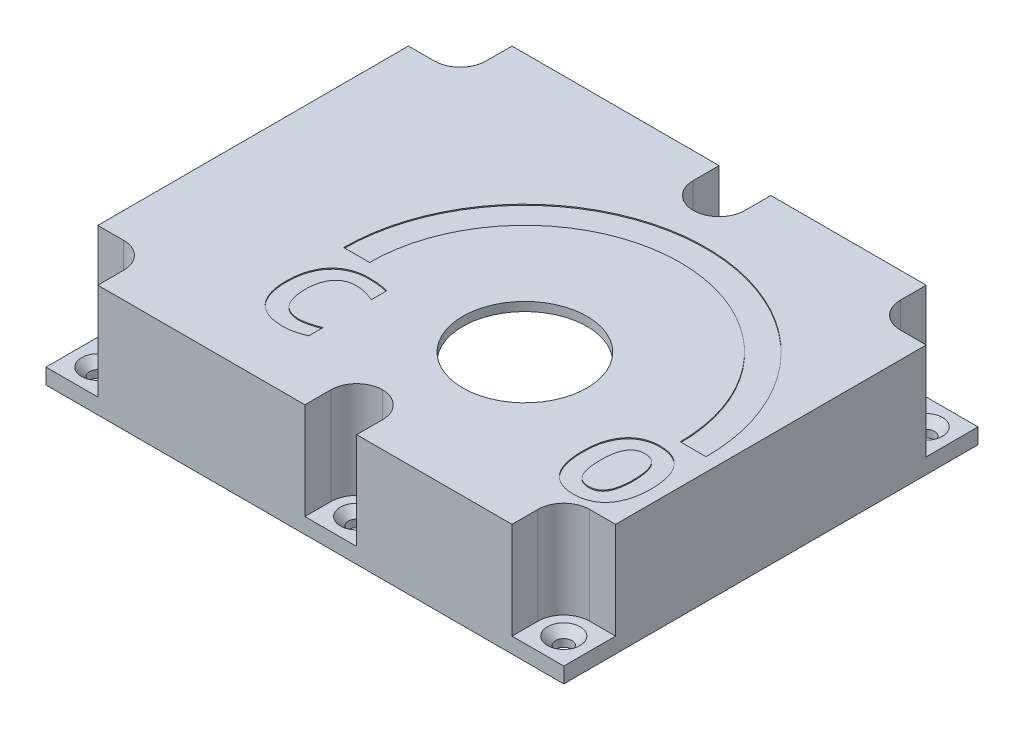
from build123d import *

# Parameters (mm, degrees)
BOSS_EXTRUDE4_DEPTH                          = 20
BOSS_EXTRUDE5_DEPTH                          = 3
BOSS_EXTRUDE6_DEPTH                          = 1.7
CSK_FOR_M3_COUNTERSUNK_FLAT_HEAD_SCR_2_COUNT = 2
CSK_FOR_M3_COUNTERSUNK_FLAT_HEAD_SCR_2_PITCH = 89.998
CSK_FOR_M3_COUNTERSUNK_FLAT_HEAD_SCR_3_COUNT = 2
CSK_FOR_M3_COUNTERSUNK_FLAT_HEAD_SCR_3_PITCH = 114.014735925
CSK_FOR_M3_COUNTERSUNK_FLAT_HEAD_SCR_4_COUNT = 2
CSK_FOR_M3_COUNTERSUNK_FLAT_HEAD_SCR_4_PITCH = 69.998
CSK_FOR_M3_COUNTERSUNK_FLAT_HEAD_SCR_5_COUNT = 2
CSK_FOR_M3_COUNTERSUNK_FLAT_HEAD_SCR_5_PITCH = 86.020462728
CSK_FOR_M3_COUNTERSUNK_FLAT_HEAD_SCR_6_COUNT = 2
CSK_FOR_M3_COUNTERSUNK_FLAT_HEAD_SCR_6_PITCH = 49.998
SKETCH7_R                                    = 12
CUT_EXTRUDE1_DEPTH                           = 69.856850528
CUT_EXTRUDE2_DEPTH                           = 0.2


with BuildPart() as part:
    # Sketch1 → Boss-Extrude4 (new body)
    with BuildSketch(Plane(origin=(0, 0, 0), x_dir=(1, 0, 0), z_dir=(0, 1, 0))):
        with BuildLine():
            Line((-49.242001852, 28.84175066), (-44.241001852, 28.84175066))
            ThreePointArc((-44.241001852, 28.84175066), (-40.706175053, 30.305923861), (-39.242001852, 33.84075066))
            Line((-39.242001852, 33.84075066), (-39.242001852, 38.84175066))
            Line((-39.242001852, 38.84175066), (0.757998148, 38.84175066))
            Line((0.757998148, 38.84175066), (0.757998148, 33.84075066))
            ThreePointArc((0.757998148, 33.84075066), (2.222171348, 30.305923861), (5.756998148, 28.84175066))
            Line((5.756998148, 28.84175066), (5.758998148, 28.84175066))
            ThreePointArc((5.758998148, 28.84175066), (9.293824947, 30.305923861), (10.757998148, 33.84075066))
            Line((10.757998148, 33.84075066), (10.757998148, 38.84175066))
            Line((10.757998148, 38.84175066), (40.757998148, 38.84175066))
            Line((40.757998148, 38.84175066), (40.757998148, 33.84075066))
            ThreePointArc((40.757998148, 33.84075066), (42.222171348, 30.305923861), (45.756998148, 28.84175066))
            Line((45.756998148, 28.84175066), (50.757998148, 28.84175066))
            Line((50.757998148, 28.84175066), (50.757998148, -31.15824934))
            Line((50.757998148, -31.15824934), (45.756998148, -31.15824934))
            ThreePointArc((45.756998148, -31.15824934), (42.222171348, -32.62242254), (40.757998148, -36.15724934))
            Line((40.757998148, -36.15724934), (40.757998148, -41.15824934))
            Line((40.757998148, -41.15824934), (10.757998148, -41.15824934))
            Line((10.757998148, -41.15824934), (10.757998148, -36.15724934))
            ThreePointArc((10.757998148, -36.15724934), (9.293824947, -32.62242254), (5.758998148, -31.15824934))
            Line((5.758998148, -31.15824934), (5.756998148, -31.15824934))
            ThreePointArc((5.756998148, -31.15824934), (2.222171348, -32.62242254), (0.757998148, -36.15724934))
            Line((0.757998148, -36.15724934), (0.757998148, -41.15824934))
            Line((0.757998148, -41.15824934), (-39.242001852, -41.15824934))
            Line((-39.242001852, -41.15824934), (-39.242001852, -36.15724934))
            ThreePointArc((-39.242001852, -36.15724934), (-40.706175053, -32.62242254), (-44.241001852, -31.15824934))
            Line((-44.241001852, -31.15824934), (-49.242001852, -31.15824934))
            Line((-49.242001852, -31.15824934), (-49.242001852, 28.84175066))
        make_face()
        with BuildLine():
            Line((-47.742001852, 27.34175066), (-44.241001852, 27.34175066))
            ThreePointArc((-44.241001852, 27.34175066), (-39.645514881, 29.245263689), (-37.742001852, 33.84075066))
            Line((-37.742001852, 33.84075066), (-37.742001852, 37.34175066))
            Line((-37.742001852, 37.34175066), (-0.742001852, 37.34175066))
            Line((-0.742001852, 37.34175066), (-0.742001852, 33.84075066))
            ThreePointArc((-0.742001852, 33.84075066), (1.161511177, 29.245263689), (5.756998148, 27.34175066))
            Line((5.756998148, 27.34175066), (5.758998148, 27.34175066))
            ThreePointArc((5.758998148, 27.34175066), (10.354485119, 29.245263689), (12.257998148, 33.84075066))
            Line((12.257998148, 33.84075066), (12.257998148, 37.34175066))
            Line((12.257998148, 37.34175066), (39.257998148, 37.34175066))
            Line((39.257998148, 37.34175066), (39.257998148, 33.84075066))
            ThreePointArc((39.257998148, 33.84075066), (41.161511177, 29.245263689), (45.756998148, 27.34175066))
            Line((45.756998148, 27.34175066), (49.257998148, 27.34175066))
            Line((49.257998148, 27.34175066), (49.257998148, -29.65824934))
            Line((49.257998148, -29.65824934), (45.756998148, -29.65824934))
            ThreePointArc((45.756998148, -29.65824934), (41.161511177, -31.561762369), (39.257998148, -36.15724934))
            Line((39.257998148, -36.15724934), (39.257998148, -39.65824934))
            Line((39.257998148, -39.65824934), (12.257998148, -39.65824934))
            Line((12.257998148, -39.65824934), (12.257998148, -36.15724934))
            ThreePointArc((12.257998148, -36.15724934), (10.354485119, -31.561762369), (5.758998148, -29.65824934))
            Line((5.758998148, -29.65824934), (5.756998148, -29.65824934))
            ThreePointArc((5.756998148, -29.65824934), (1.161511177, -31.561762369), (-0.742001852, -36.15724934))
            Line((-0.742001852, -36.15724934), (-0.742001852, -39.65824934))
            Line((-0.742001852, -39.65824934), (-37.742001852, -39.65824934))
            Line((-37.742001852, -39.65824934), (-37.742001852, -36.15724934))
            ThreePointArc((-37.742001852, -36.15724934), (-39.645514881, -31.561762369), (-44.241001852, -29.65824934))
            Line((-44.241001852, -29.65824934), (-47.742001852, -29.65824934))
            Line((-47.742001852, -29.65824934), (-47.742001852, 27.34175066))
        make_face(mode=Mode.SUBTRACT)
    extrude(amount=BOSS_EXTRUDE4_DEPTH)

    # Sketch2 → Boss-Extrude5 (add)
    with BuildSketch(Plane.XZ):
        with BuildLine():
            Line((0.757998148, -38.84175066), (10.757998148, -38.84175066))
            Line((10.757998148, -38.84175066), (10.757998148, -33.84075066))
            ThreePointArc((10.757998148, -33.84075066), (9.293824947, -30.305923861), (5.758998148, -28.84175066))
            Line((5.758998148, -28.84175066), (5.756998148, -28.84175066))
            ThreePointArc((5.756998148, -28.84175066), (2.222171348, -30.305923861), (0.757998148, -33.84075066))
            Line((0.757998148, -33.84075066), (0.757998148, -38.84175066))
        make_face()
        with BuildLine():
            Line((-49.242001852, -38.84175066), (-39.242001852, -38.84175066))
            Line((-39.242001852, -38.84175066), (-39.242001852, -33.84075066))
            ThreePointArc((-39.242001852, -33.84075066), (-40.706175053, -30.305923861), (-44.241001852, -28.84175066))
            Line((-44.241001852, -28.84175066), (-49.242001852, -28.84175066))
            Line((-49.242001852, -28.84175066), (-49.242001852, -38.84175066))
        make_face()
        with BuildLine():
            Line((-49.242001852, 41.15824934), (-39.242001852, 41.15824934))
            Line((-39.242001852, 41.15824934), (-39.242001852, 36.15724934))
            ThreePointArc((-39.242001852, 36.15724934), (-40.706175053, 32.62242254), (-44.241001852, 31.15824934))
            Line((-44.241001852, 31.15824934), (-49.242001852, 31.15824934))
            Line((-49.242001852, 31.15824934), (-49.242001852, 41.15824934))
        make_face()
        with BuildLine():
            Line((50.757998148, 41.15824934), (40.757998148, 41.15824934))
            Line((40.757998148, 41.15824934), (40.757998148, 36.15724934))
            ThreePointArc((40.757998148, 36.15724934), (42.222171348, 32.62242254), (45.756998148, 31.15824934))
            Line((45.756998148, 31.15824934), (50.757998148, 31.15824934))
            Line((50.757998148, 31.15824934), (50.757998148, 41.15824934))
        make_face()
        with BuildLine():
            Line((50.757998148, -38.84175066), (40.757998148, -38.84175066))
            Line((40.757998148, -38.84175066), (40.757998148, -33.84075066))
            ThreePointArc((40.757998148, -33.84075066), (42.222171348, -30.305923861), (45.756998148, -28.84175066))
            Line((45.756998148, -28.84175066), (50.757998148, -28.84175066))
            Line((50.757998148, -28.84175066), (50.757998148, -38.84175066))
        make_face()
        with BuildLine():
            Line((0.757998148, 41.15824934), (10.757998148, 41.15824934))
            Line((10.757998148, 41.15824934), (10.757998148, 36.15724934))
            ThreePointArc((10.757998148, 36.15724934), (9.293824947, 32.62242254), (5.758998148, 31.15824934))
            Line((5.758998148, 31.15824934), (5.756998148, 31.15824934))
            ThreePointArc((5.756998148, 31.15824934), (2.222171348, 32.62242254), (0.757998148, 36.15724934))
            Line((0.757998148, 36.15724934), (0.757998148, 41.15824934))
        make_face()
    extrude(amount=-BOSS_EXTRUDE5_DEPTH)

    # Sketch3 → Boss-Extrude6 (add)
    with BuildSketch(Plane(origin=(0, 20, 0), x_dir=(1, 0, 0), z_dir=(0, 1, 0))):
        with BuildLine():
            ThreePointArc((0.757998148, 33.84075066), (2.222171348, 30.305923861), (5.756998148, 28.84175066))
            Line((5.756998148, 28.84175066), (5.758998148, 28.84175066))
            ThreePointArc((5.758998148, 28.84175066), (9.293824947, 30.305923861), (10.757998148, 33.84075066))
            Line((10.757998148, 33.84075066), (10.757998148, 38.84175066))
            Line((10.757998148, 38.84175066), (40.757998148, 38.84175066))
            Line((40.757998148, 38.84175066), (40.757998148, 33.84075066))
            ThreePointArc((40.757998148, 33.84075066), (42.222171348, 30.305923861), (45.756998148, 28.84175066))
            Line((45.756998148, 28.84175066), (50.757998148, 28.84175066))
            Line((50.757998148, 28.84175066), (50.757998148, -31.15824934))
            Line((50.757998148, -31.15824934), (45.756998148, -31.15824934))
            ThreePointArc((45.756998148, -31.15824934), (42.222171348, -32.62242254), (40.757998148, -36.15724934))
            Line((40.757998148, -36.15724934), (40.757998148, -41.15824934))
            Line((40.757998148, -41.15824934), (10.757998148, -41.15824934))
            Line((10.757998148, -41.15824934), (10.757998148, -36.15724934))
            ThreePointArc((10.757998148, -36.15724934), (9.293824947, -32.62242254), (5.758998148, -31.15824934))
            Line((5.758998148, -31.15824934), (5.756998148, -31.15824934))
            ThreePointArc((5.756998148, -31.15824934), (2.222171348, -32.62242254), (0.757998148, -36.15724934))
            Line((0.757998148, -36.15724934), (0.757998148, -41.15824934))
            Line((0.757998148, -41.15824934), (-39.242001852, -41.15824934))
            Line((-39.242001852, -41.15824934), (-39.242001852, -36.15724934))
            ThreePointArc((-39.242001852, -36.15724934), (-40.706175053, -32.62242254), (-44.241001852, -31.15824934))
            Line((-44.241001852, -31.15824934), (-49.242001852, -31.15824934))
            Line((-49.242001852, -31.15824934), (-49.242001852, 28.84175066))
            Line((-49.242001852, 28.84175066), (-44.241001852, 28.84175066))
            ThreePointArc((-44.241001852, 28.84175066), (-40.706175053, 30.305923861), (-39.242001852, 33.84075066))
            Line((-39.242001852, 33.84075066), (-39.242001852, 38.84175066))
            Line((-39.242001852, 38.84175066), (0.757998148, 38.84175066))
            Line((0.757998148, 38.84175066), (0.757998148, 33.84075066))
        make_face()
    extrude(amount=BOSS_EXTRUDE6_DEPTH)

    # Sketch5 → CSK for M3 Countersunk Flat Head Screw1 (revolve, cut)
    with BuildSketch(Plane(origin=(-44.241001852, 3, -33.84075066), x_dir=(0, 0, 1), z_dir=(1, 0, 0))):
        Polygon((0, 0), (0, 3), (1.6, 3), (1.6, 1.55), (3.15, 0), align=None)
    csk_for_m3_countersunk_flat_head_screw1 = revolve(axis=Axis((-44.241001852, 9.35, -33.84075066), (0, -1, 0)), mode=Mode.SUBTRACT)

    # CSK for M3 Countersunk Flat Head Scr 2: CSK for M3 Countersunk Flat Head Screw1 ×2
    with Locations(*[(i * CSK_FOR_M3_COUNTERSUNK_FLAT_HEAD_SCR_2_PITCH, 0, 0) for i in range(1, CSK_FOR_M3_COUNTERSUNK_FLAT_HEAD_SCR_2_COUNT)]):
        add(csk_for_m3_countersunk_flat_head_screw1, mode=Mode.SUBTRACT)

    # CSK for M3 Countersunk Flat Head Scr 3: CSK for M3 Countersunk Flat Head Screw1 ×2
    with Locations(*[Vector(0.789354106467132, 0, 0.6139381846761739) * (i * CSK_FOR_M3_COUNTERSUNK_FLAT_HEAD_SCR_3_PITCH) for i in range(1, CSK_FOR_M3_COUNTERSUNK_FLAT_HEAD_SCR_3_COUNT)]):
        add(csk_for_m3_countersunk_flat_head_screw1, mode=Mode.SUBTRACT)

    # CSK for M3 Countersunk Flat Head Scr 4: CSK for M3 Countersunk Flat Head Screw1 ×2
    with Locations(*[(0, 0, i * CSK_FOR_M3_COUNTERSUNK_FLAT_HEAD_SCR_4_PITCH) for i in range(1, CSK_FOR_M3_COUNTERSUNK_FLAT_HEAD_SCR_4_COUNT)]):
        add(csk_for_m3_countersunk_flat_head_screw1, mode=Mode.SUBTRACT)

    # CSK for M3 Countersunk Flat Head Scr 5: CSK for M3 Countersunk Flat Head Screw1 ×2
    with Locations(*[Vector(0.5812337950086401, 0, 0.8137366131248208) * (i * CSK_FOR_M3_COUNTERSUNK_FLAT_HEAD_SCR_5_PITCH) for i in range(1, CSK_FOR_M3_COUNTERSUNK_FLAT_HEAD_SCR_5_COUNT)]):
        add(csk_for_m3_countersunk_flat_head_screw1, mode=Mode.SUBTRACT)

    # CSK for M3 Countersunk Flat Head Scr 6: CSK for M3 Countersunk Flat Head Screw1 ×2
    with Locations(*[(i * CSK_FOR_M3_COUNTERSUNK_FLAT_HEAD_SCR_6_PITCH, 0, 0) for i in range(1, CSK_FOR_M3_COUNTERSUNK_FLAT_HEAD_SCR_6_COUNT)]):
        add(csk_for_m3_countersunk_flat_head_screw1, mode=Mode.SUBTRACT)

    # Sketch7 → Cut-Extrude1 (cut, through all)
    with BuildSketch(Plane(origin=(0, 21.7, 0), x_dir=(1, 0, 0), z_dir=(0, 1, 0))):
        with Locations(Location((13.196395148, -11.10824934, 0), (0, 0, 270))):
            Circle(SKETCH7_R)
    extrude(amount=-CUT_EXTRUDE1_DEPTH, mode=Mode.SUBTRACT)

    # Sketch8 → Cut-Extrude2 (cut)
    with BuildSketch(Plane(origin=(0, 21.7, 0), x_dir=(1, 0, 0), z_dir=(0, 1, 0))):
        with BuildLine():
            Line((-21.803604852, -11.10824934), (-16.803604852, -11.10824934))
            ThreePointArc((-16.803604852, -11.10824934), (13.196395148, 18.89175066), (43.196395148, -11.10824934))
            Line((43.196395148, -11.10824934), (48.196395148, -11.10824934))
            ThreePointArc((48.196395148, -11.10824934), (13.196395148, 23.89175066), (-21.803604852, -11.10824934))
        make_face()
        with BuildLine():
            add(Edge.make_bspline(
                [(-10.396498961, -29.259797973), (-10.573314527, -29.335278245), (-10.920221238, -29.48336822), (-11.444570062, -29.671129892), (-11.959348773, -29.831566568), (-12.469472256, -29.962814931), (-12.98054775, -30.067349926), (-13.499084516, -30.132721024), (-14.027284378, -30.179669837), (-14.383105842, -30.184758925), (-14.563165627, -30.187334205)],
                knots=[0, 0, 0, 0, 1.072602722, 2.104413604, 3.106297595, 4.08050826, 5.042709706, 6.014913564, 6.995467464, 8, 8, 8, 8], degree=3))
            add(Edge.make_bspline(
                [(-14.563165627, -30.187334205), (-14.844837842, -30.181169268), (-15.391718815, -30.169199729), (-16.188564586, -30.073701447), (-16.934741206, -29.915932829), (-17.632891547, -29.695682978), (-18.277842104, -29.407901385), (-18.872657472, -29.058520638), (-19.416216233, -28.647462597), (-19.904749664, -28.17249708), (-20.339115032, -27.636928751), (-20.712222144, -27.035932958), (-21.035722157, -26.378842147), (-21.300038931, -25.659761229), (-21.505712873, -24.88080498), (-21.651445503, -24.041987971), (-21.744612489, -23.143539517), (-21.753985988, -22.524533076), (-21.758817801, -22.205450147)],
                knots=[0, 0, 0, 0, 1.102605573, 2.140764961, 3.136846793, 4.08496906, 5.001529512, 5.896051515, 6.780328523, 7.66316301, 8.557497515, 9.473264751, 10.427030373, 11.420482266, 12.467702166, 13.577100782, 14.751053738, 16, 16, 16, 16], degree=3))
            add(Edge.make_bspline(
                [(-21.758817801, -22.205450147), (-21.753020793, -21.877873923), (-21.741720306, -21.239308133), (-21.64068115, -20.310656542), (-21.485903156, -19.435444011), (-21.255249511, -18.61948282), (-20.971529992, -17.858758099), (-20.625119114, -17.161267504), (-20.230584606, -16.52061109), (-19.774598046, -15.945511472), (-19.266115236, -15.431674365), (-18.703110104, -14.983821646), (-18.092449887, -14.596458925), (-17.427230473, -14.281090705), (-16.716558276, -14.032181855), (-15.962162969, -13.849280887), (-15.163954116, -13.744463707), (-14.617819052, -13.730637005), (-14.338527946, -13.723566089)],
                knots=[0, 0, 0, 0, 1.232307787, 2.402218284, 3.511138658, 4.573037126, 5.588482404, 6.562047137, 7.499038646, 8.414657469, 9.317692522, 10.213424542, 11.116219401, 12.033010505, 12.977368732, 13.94518829, 14.949178196, 16, 16, 16, 16], degree=3))
            add(Edge.make_bspline(
                [(-14.338527946, -13.723566089), (-14.159751698, -13.723403967), (-13.812965973, -13.723089488), (-13.305838054, -13.745265677), (-12.819430822, -13.764983228), (-12.343931668, -13.817102901), (-11.869265438, -13.874419396), (-11.389814283, -13.964024422), (-10.895703153, -14.055867222), (-10.56510249, -14.142931939), (-10.396498961, -14.187334205)],
                knots=[0, 0, 0, 0, 1.077376558, 2.089868288, 3.059369192, 4.010411707, 4.972009834, 5.940198088, 6.949518525, 8, 8, 8, 8], degree=3))
            Line((-10.396498961, -14.187334205), (-10.396498961, -17.201826959))
            add(Edge.make_bspline(
                [(-10.396498961, -17.201826959), (-10.569545275, -17.122473778), (-10.908395722, -16.967088436), (-11.421302513, -16.773426911), (-11.919172753, -16.60694656), (-12.406092719, -16.486678353), (-12.872549614, -16.390860897), (-13.320279318, -16.326209797), (-13.745944181, -16.284176232), (-14.0232221, -16.277513932), (-14.157368526, -16.274290727)],
                knots=[0, 0, 0, 0, 1.170030163, 2.291093263, 3.368831198, 4.395296508, 5.372370687, 6.295361994, 7.175300008, 8, 8, 8, 8], degree=3))
            add(Edge.make_bspline(
                [(-14.157368526, -16.274290727), (-14.343626832, -16.278839992), (-14.703318662, -16.287625284), (-15.222789202, -16.36404356), (-15.700199105, -16.493321097), (-16.134970083, -16.676444744), (-16.530703695, -16.904056165), (-16.891918513, -17.171701803), (-17.212154031, -17.487149994), (-17.495643502, -17.840450571), (-17.743503894, -18.232334448), (-17.956209187, -18.659928664), (-18.134839804, -19.123232356), (-18.273477859, -19.620097953), (-18.382242945, -20.145567331), (-18.456094608, -20.697759002), (-18.505618896, -21.274592286), (-18.510136811, -21.667902012), (-18.51244099, -21.868493625)],
                knots=[0, 0, 0, 0, 1.109729706, 2.143049175, 3.121026665, 4.050204485, 4.946654748, 5.836403406, 6.722153568, 7.618170183, 8.530804457, 9.480502004, 10.460411604, 11.48580219, 12.551706219, 13.656287425, 14.804684813, 16, 16, 16, 16], degree=3))
            add(Edge.make_bspline(
                [(-18.51244099, -21.868493625), (-18.510625079, -22.079989997), (-18.507080983, -22.492765429), (-18.451576354, -23.093326732), (-18.380386672, -23.661946317), (-18.267318965, -24.193374217), (-18.124827167, -24.689220238), (-17.941614702, -25.144345115), (-17.729530403, -25.564042085), (-17.477751205, -25.943278594), (-17.19106763, -26.284382687), (-16.862449902, -26.578045712), (-16.498909655, -26.831426004), (-16.098347729, -27.043226346), (-15.656971004, -27.20574791), (-15.177681009, -27.319735733), (-14.660975399, -27.395425331), (-14.302581938, -27.401558462), (-14.117513454, -27.404725509)],
                knots=[0, 0, 0, 0, 1.256876421, 2.453033611, 3.583260076, 4.661975506, 5.679853963, 6.646528144, 7.574590913, 8.470745685, 9.346915849, 10.216322401, 11.082788599, 11.975686973, 12.902638023, 13.870910894, 14.900573425, 16, 16, 16, 16], degree=3))
            add(Edge.make_bspline(
                [(-14.117513454, -27.404725509), (-13.974817092, -27.401246203), (-13.677465511, -27.393996003), (-13.219150884, -27.330924396), (-12.742242334, -27.240946888), (-12.254629302, -27.128925698), (-11.768709573, -26.991840752), (-11.290657609, -26.832856419), (-10.832763086, -26.661925044), (-10.538607842, -26.537365193), (-10.396498961, -26.477189277)],
                knots=[0, 0, 0, 0, 0.887372101, 1.849111607, 2.873273884, 3.906654629, 4.960374994, 6.012916101, 7.040022999, 8, 8, 8, 8], degree=3))
            Line((-10.396498961, -26.477189277), (-10.396498961, -29.259797973))
        make_face()
        with BuildLine():
            add(Edge.make_bspline(
                [(48.288169612, -21.882986379), (48.281934393, -22.232222204), (48.2698927, -22.906679687), (48.17715597, -23.882292954), (48.015343131, -24.782740229), (47.790807674, -25.609269454), (47.511781895, -26.361835667), (47.185018858, -27.045997379), (46.809113946, -27.660682489), (46.383101569, -28.205238884), (45.911242002, -28.677411264), (45.407323998, -29.092363154), (44.85745519, -29.434113844), (44.274040016, -29.713034081), (43.661199668, -29.927102902), (43.024063519, -30.072886633), (42.36864252, -30.17326193), (41.922609317, -30.182615447), (41.697589902, -30.187334205)],
                knots=[0, 0, 0, 0, 1.399094986, 2.701985343, 3.921606295, 5.060250114, 6.128937938, 7.133140352, 8.093336986, 9.010033534, 9.896223585, 10.76303321, 11.619598843, 12.483160966, 13.349322064, 14.214333538, 15.099148625, 16, 16, 16, 16], degree=3))
            add(Edge.make_bspline(
                [(41.697589902, -30.187334205), (41.44000843, -30.181503098), (40.939787298, -30.170179135), (40.21389656, -30.070266862), (39.536750234, -29.909248691), (38.908523545, -29.680771258), (38.33060482, -29.38474179), (37.801075928, -29.024564694), (37.322771526, -28.59555895), (36.893778525, -28.103709394), (36.515428588, -27.548624741), (36.190028737, -26.932860844), (35.913561348, -26.258129713), (35.692805661, -25.524383717), (35.512369675, -24.734451413), (35.394752843, -23.884599435), (35.315565874, -22.976275047), (35.307052353, -22.350562067), (35.302662366, -22.027913915)],
                knots=[0, 0, 0, 0, 1.046182631, 2.031678192, 2.97076483, 3.86965419, 4.740954983, 5.602542005, 6.464464361, 7.344346083, 8.248138063, 9.187737429, 10.169205071, 11.206116273, 12.297806163, 13.458167033, 14.68930686, 16, 16, 16, 16], degree=3))
            add(Edge.make_bspline(
                [(35.302662366, -22.027913915), (35.308804581, -21.678663715), (35.32066666, -21.004178471), (35.414518389, -20.030155894), (35.571641055, -19.130406785), (35.795346459, -18.304342614), (36.080866733, -17.552727346), (36.404530236, -16.865517524), (36.781893285, -16.250290991), (37.207695772, -15.705662695), (37.679564201, -15.233418033), (38.18364063, -14.818812105), (38.732434806, -14.47604017), (39.31772961, -14.202134026), (39.931104165, -13.98760923), (40.567620863, -13.837798391), (41.223403685, -13.737612608), (41.668228677, -13.728284623), (41.893242076, -13.723566089)],
                knots=[0, 0, 0, 0, 1.399147349, 2.702086469, 3.916134137, 5.054820572, 6.125245074, 7.133847534, 8.094080105, 9.010810961, 9.897034179, 10.763876246, 11.620473937, 12.481991629, 13.348185144, 14.219056267, 15.099114909, 16, 16, 16, 16], degree=3))
            add(Edge.make_bspline(
                [(41.893242076, -13.723566089), (42.150822259, -13.729399085), (42.651040889, -13.740726715), (43.376949285, -13.840613108), (44.054033257, -14.001722661), (44.682478905, -14.229879205), (45.259009864, -14.526744898), (45.790904607, -14.882232572), (46.267852401, -15.31199109), (46.697234797, -15.803427449), (47.074269617, -16.358060412), (47.401916085, -16.971421728), (47.67628349, -17.644659529), (47.899310013, -18.377695574), (48.078216497, -19.169303518), (48.196136077, -20.022669446), (48.275137133, -20.933433026), (48.283741368, -21.560342155), (48.288169612, -21.882986379)],
                knots=[0, 0, 0, 0, 1.04600235, 2.031328089, 2.970252902, 3.868987364, 4.740138012, 5.59881955, 6.460593378, 7.340323477, 8.243959714, 9.179069388, 10.160367901, 11.192410958, 12.288699193, 13.453715767, 14.689532722, 16, 16, 16, 16], degree=3))
        make_face()
        with BuildLine():
            add(Edge.make_bspline(
                [(45.0417928, -22.027913915), (45.040225405, -21.803214961), (45.037189508, -21.367994285), (44.999190914, -20.737142621), (44.943917298, -20.150388866), (44.861171742, -19.60824035), (44.752760888, -19.110992155), (44.622836769, -18.656884232), (44.473489196, -18.245257262), (44.293473833, -17.879485614), (44.093418679, -17.552538174), (43.853507371, -17.27299502), (43.583515066, -17.037688374), (43.288073917, -16.83674951), (42.956457265, -16.688113866), (42.595053834, -16.585103552), (42.204928095, -16.517362643), (41.934600402, -16.509977299), (41.795415989, -16.506174785)],
                knots=[0, 0, 0, 0, 1.486095503, 2.8784268, 4.178896477, 5.383313849, 6.50370181, 7.542880676, 8.505944191, 9.395566462, 10.23559869, 11.034510805, 11.821349203, 12.599050339, 13.389126436, 14.213243526, 15.080047443, 16, 16, 16, 16], degree=3))
            add(Edge.make_bspline(
                [(41.795415989, -16.506174785), (41.656267155, -16.51008969), (41.387200015, -16.517659802), (40.998193364, -16.583343815), (40.640793843, -16.695411249), (40.315360364, -16.852481006), (40.020144666, -17.051551071), (39.754918716, -17.29348232), (39.5134137, -17.575413198), (39.300167578, -17.899492523), (39.114799885, -18.264271853), (38.961586333, -18.670133899), (38.82570284, -19.112294485), (38.723763088, -19.595262547), (38.64357947, -20.114182592), (38.592753572, -20.670889863), (38.553443677, -21.264073201), (38.5505352, -21.672767641), (38.549039177, -21.882986379)],
                knots=[0, 0, 0, 0, 0.940493395, 1.818598556, 2.65806311, 3.465325826, 4.253609174, 5.057352584, 5.885618443, 6.757702066, 7.674492596, 8.646685703, 9.687886232, 10.799631583, 11.981266591, 13.236822997, 14.578714251, 16, 16, 16, 16], degree=3))
            add(Edge.make_bspline(
                [(38.549039177, -21.882986379), (38.550727647, -22.10767411), (38.553998052, -22.542873049), (38.590365836, -23.173998761), (38.651269166, -23.760353689), (38.73463683, -24.303321253), (38.837134542, -24.802670026), (38.966003107, -25.257752793), (39.124163373, -25.666130325), (39.297645459, -26.035288534), (39.507513364, -26.358106427), (39.743109031, -26.63993458), (40.010630263, -26.879555723), (40.310786004, -27.072373774), (40.640325508, -27.222528662), (40.999391713, -27.325793092), (41.387062149, -27.393760701), (41.656220161, -27.400987928), (41.795415989, -27.404725509)],
                knots=[0, 0, 0, 0, 1.486662466, 2.879524953, 4.181300558, 5.38617743, 6.513130284, 7.552705609, 8.511484829, 9.408629925, 10.246547046, 11.051854149, 11.833006184, 12.613299248, 13.403676768, 14.220441868, 15.079696471, 16, 16, 16, 16], degree=3))
            add(Edge.make_bspline(
                [(41.795415989, -27.404725509), (41.934533374, -27.400686016), (42.204730882, -27.392840405), (42.595327446, -27.328419503), (42.952525359, -27.214376077), (43.28193185, -27.062564925), (43.576272441, -26.858494522), (43.846933477, -26.620005999), (44.084223064, -26.334853646), (44.295006374, -26.011550616), (44.473937764, -25.644700711), (44.635569393, -25.244113434), (44.759126595, -24.799572539), (44.864944876, -24.318396244), (44.941842391, -23.797553441), (44.99961684, -23.240306536), (45.036963672, -22.646779151), (45.040152549, -22.23811637), (45.0417928, -22.027913915)],
                knots=[0, 0, 0, 0, 0.940029382, 1.82575022, 2.664800606, 3.468147471, 4.267377886, 5.076798435, 5.899366548, 6.766536204, 7.679194691, 8.653886611, 9.682108903, 10.79330575, 11.982426563, 13.238186273, 14.579415474, 16, 16, 16, 16], degree=3))
        make_face(mode=Mode.SUBTRACT)
    extrude(amount=-CUT_EXTRUDE2_DEPTH, mode=Mode.SUBTRACT)


solid = part.part
